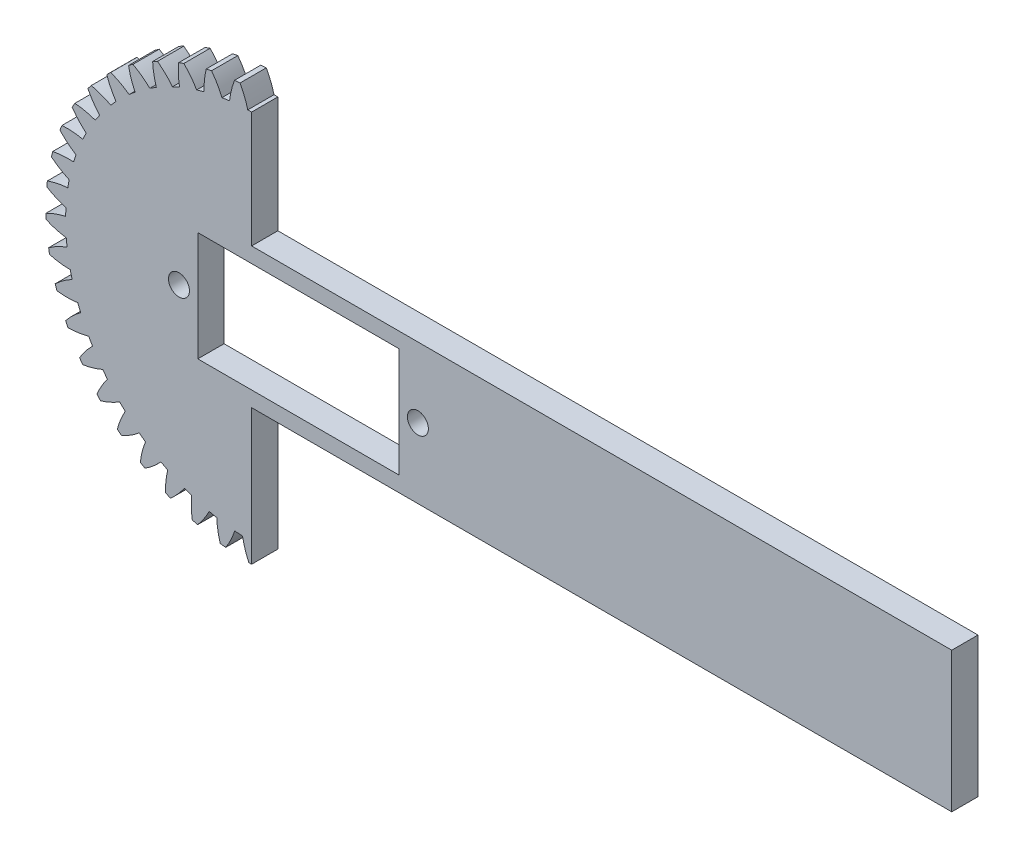
from build123d import *

# Parameters (mm, degrees)
MODEL_R             = 2.5
BOSS_EXTRUDE1_DEPTH = 3
CUT_EXTRUDE1_DEPTH  = 3
SKETCH5_W           = 82.5
SKETCH5_H           = 16
BOSS_EXTRUDE2_DEPTH = 3
SKETCH6_R           = 1.2
SKETCH6_W           = 23
SKETCH6_H           = 12.5
CUT_EXTRUDE3_DEPTH  = 3


with BuildPart() as part:
    # Model → Boss-Extrude1 (new body)
    with BuildSketch(Plane.XY):
        with BuildLine():
            ThreePointArc((32.442634493, 93.418604181), (32.407825649, 93.107382285), (32.377167165, 92.795724168))
            ThreePointArc((32.377167165, 92.795724168), (33.438114337, 92.242398237), (34.563087863, 91.834705887))
            ThreePointArc((34.563087863, 91.834705887), (34.543034507, 91.392542803), (34.532195277, 90.950057955))
            ThreePointArc((34.532195277, 90.950057955), (33.381522949, 90.62183291), (32.284562125, 90.143862787))
            ThreePointArc((32.284562125, 90.143862787), (32.293405755, 89.830825225), (32.306420064, 89.517933307))
            ThreePointArc((32.306420064, 89.517933307), (33.434050257, 89.117647614), (34.604815427, 88.870488953))
            ThreePointArc((34.604815427, 88.870488953), (34.646494435, 88.429838082), (34.697342681, 87.990150937))
            ThreePointArc((34.697342681, 87.990150937), (33.603548714, 87.504977519), (32.583784022, 86.878991529))
            ThreePointArc((32.583784022, 86.878991529), (32.636107994, 86.570231223), (32.692541788, 86.262195589))
            ThreePointArc((32.692541788, 86.262195589), (33.864906962, 86.02274124), (35.058676163, 85.940926928))
            ThreePointArc((35.058676163, 85.940926928), (35.161276302, 85.510365038), (35.272822319, 85.082033606))
            ThreePointArc((35.272822319, 85.082033606), (34.25719617, 84.449355164), (33.334476169, 83.687537413))
            ThreePointArc((33.334476169, 83.687537413), (33.429262057, 83.38906403), (33.528016915, 83.091880244))
            ThreePointArc((33.528016915, 83.091880244), (34.722298316, 83.017917945), (35.915836189, 83.103040406))
            ThreePointArc((35.915836189, 83.103040406), (36.077360464, 82.690947894), (36.247433137, 82.282309159))
            ThreePointArc((36.247433137, 82.282309159), (35.329742812, 81.51444006), (34.522027197, 80.631618462))
            ThreePointArc((34.522027197, 80.631618462), (34.657430102, 80.349241448), (34.796583874, 80.068693854))
            ThreePointArc((34.796583874, 80.068693854), (35.989536173, 80.161663197), (37.15961186, 80.412065619))
            ThreePointArc((37.15961186, 80.412065619), (37.376916385, 80.026463398), (37.602205442, 79.645471048))
            ThreePointArc((37.602205442, 79.645471048), (36.800312739, 78.75735699), (36.123322777, 77.770714665))
            ThreePointArc((36.123322777, 77.770714665), (36.296707235, 77.509930166), (36.47355145, 77.251479304))
            ThreePointArc((36.47355145, 77.251479304), (37.641955188, 77.509570746), (38.765794497, 77.920379331))
            ThreePointArc((38.765794497, 77.920379331), (39.034649686, 77.568772709), (39.310770133, 77.222842327))
            ThreePointArc((39.310770133, 77.222842327), (38.640282982, 76.23176944), (38.107195512, 75.160510257))
            ThreePointArc((38.107195512, 75.160510257), (38.315186791, 74.926394148), (38.526279379, 74.69507047))
            ThreePointArc((38.526279379, 74.69507047), (39.647392905, 75.113260555), (40.703121583, 75.676479381))
            ThreePointArc((40.703121583, 75.676479381), (41.018294476, 75.36571198), (41.339871941, 75.061576708))
            ThreePointArc((41.339871941, 75.061576708), (40.813840612, 73.986835098), (40.435031575, 72.8518099))
            ThreePointArc((40.435031575, 72.8518099), (40.673581362, 72.648918985), (40.914813645, 72.449224943))
            ThreePointArc((40.914813645, 72.449224943), (41.966815761, 73.019374077), (42.933885249, 73.724040729))
            ThreePointArc((42.933885249, 73.724040729), (43.289241364, 73.460161284), (43.650016708, 73.203740769))
            ThreePointArc((43.650016708, 73.203740769), (43.278679803, 72.066249059), (43.061522286, 70.88954982))
            ThreePointArc((43.061522286, 70.88954982), (43.32598748, 70.721833138), (43.592664146, 70.55765555))
            ThreePointArc((43.592664146, 70.55765555), (44.555078827, 71.268666428), (45.414666218, 72.101065373))
            ThreePointArc((45.414666218, 72.101065373), (45.803288952, 71.889209997), (46.196240094, 71.685495172))
            ThreePointArc((46.196240094, 71.685495172), (45.986825262, 70.507393345), (45.935545989, 69.311923176))
            ThreePointArc((45.935545989, 69.311923176), (46.220779078, 69.182645143), (46.507709568, 69.057179538))
            ThreePointArc((46.507709568, 69.057179538), (47.361804507, 69.895213143), (48.09717891, 70.839142682))
            ThreePointArc((48.09717891, 70.839142682), (48.511504164, 70.683434899), (48.928982756, 70.536390841))
            ThreePointArc((48.928982756, 70.536390841), (48.88556602, 69.340609308), (49.001163084, 68.149636678))
            ThreePointArc((49.001163084, 68.149636678), (49.301612328, 68.061313543), (49.603211868, 67.977001967))
            ThreePointArc((49.603211868, 67.977001967), (50.332363078, 68.925746928), (50.929211268, 69.962834545))
            ThreePointArc((50.929211268, 69.962834545), (51.361174672, 69.86630503), (51.795054968, 69.778793785))
            ThreePointArc((51.795054968, 69.778793785), (51.918481385, 68.588607074), (52.19870482, 67.42531291))
            ThreePointArc((52.19870482, 67.42531291), (52.508522317, 67.379663782), (52.818920615, 67.338147264))
            ThreePointArc((52.818920615, 67.338147264), (53.408935997, 68.379137339), (53.855641001, 69.489197304))
            ThreePointArc((53.855641001, 69.489197304), (54.296834879, 69.453724894), (54.738671894, 69.427449769))
            ThreePointArc((54.738671894, 69.427449769), (55.026539108, 68.26602351), (55.465934684, 67.153050009))
            ThreePointArc((55.465934684, 67.153050009), (55.77909019, 67.150963398), (56.092245695, 67.153050009))
            ThreePointArc((56.092245695, 67.153050009), (56.531641271, 68.26602351), (56.819508486, 69.427449769))
            ThreePointArc((56.819508486, 69.427449769), (57.2613455, 69.453724894), (57.702539378, 69.489197304))
            ThreePointArc((57.702539378, 69.489197304), (58.149244383, 68.379137339), (58.739259765, 67.338147264))
            ThreePointArc((58.739259765, 67.338147264), (59.049658062, 67.379663782), (59.35947556, 67.42531291))
            ThreePointArc((59.35947556, 67.42531291), (59.639698995, 68.588607074), (59.763125412, 69.778793785))
            ThreePointArc((59.763125412, 69.778793785), (60.197005708, 69.86630503), (60.628969112, 69.962834545))
            ThreePointArc((60.628969112, 69.962834545), (61.225817302, 68.925746928), (61.954968511, 67.977001967))
            ThreePointArc((61.954968511, 67.977001967), (62.256568052, 68.061313543), (62.557017296, 68.149636678))
            ThreePointArc((62.557017296, 68.149636678), (62.672614359, 69.340609308), (62.629197623, 70.536390841))
            ThreePointArc((62.629197623, 70.536390841), (63.046676215, 70.683434899), (63.461001469, 70.839142682))
            ThreePointArc((63.461001469, 70.839142682), (64.196375873, 69.895213143), (65.050470811, 69.057179538))
            ThreePointArc((65.050470811, 69.057179538), (65.337401302, 69.182645143), (65.622634391, 69.311923176))
            ThreePointArc((65.622634391, 69.311923176), (65.571355117, 70.507393345), (65.361940286, 71.685495172))
            ThreePointArc((65.361940286, 71.685495172), (65.754891428, 71.889209997), (66.143514162, 72.101065373))
            ThreePointArc((66.143514162, 72.101065373), (67.003101553, 71.268666428), (67.965516234, 70.55765555))
            ThreePointArc((67.965516234, 70.55765555), (68.232192899, 70.721833138), (68.496658094, 70.88954982))
            ThreePointArc((68.496658094, 70.88954982), (68.279500577, 72.066249059), (67.908163672, 73.203740769))
            ThreePointArc((67.908163672, 73.203740769), (68.268939016, 73.460161284), (68.624295131, 73.724040729))
            ThreePointArc((68.624295131, 73.724040729), (69.591364619, 73.019374077), (70.643366735, 72.449224943))
            ThreePointArc((70.643366735, 72.449224943), (70.884599018, 72.648918985), (71.123148805, 72.8518099))
            ThreePointArc((71.123148805, 72.8518099), (70.744339767, 73.986835098), (70.218308439, 75.061576708))
            ThreePointArc((70.218308439, 75.061576708), (70.539885904, 75.36571198), (70.855058797, 75.676479381))
            ThreePointArc((70.855058797, 75.676479381), (71.910787474, 75.113260555), (73.031901001, 74.69507047))
            ThreePointArc((73.031901001, 74.69507047), (73.242993589, 74.926394148), (73.450984868, 75.160510257))
            ThreePointArc((73.450984868, 75.160510257), (72.917897397, 76.23176944), (72.247410247, 77.222842327))
            ThreePointArc((72.247410247, 77.222842327), (72.523530693, 77.568772709), (72.792385882, 77.920379331))
            ThreePointArc((72.792385882, 77.920379331), (73.916225192, 77.509570746), (75.084628929, 77.251479304))
            ThreePointArc((75.084628929, 77.251479304), (75.261473145, 77.509930166), (75.434857602, 77.770714665))
            ThreePointArc((75.434857602, 77.770714665), (74.75786764, 78.75735699), (73.955974938, 79.645471048))
            ThreePointArc((73.955974938, 79.645471048), (74.181263995, 80.026463398), (74.39856852, 80.412065619))
            ThreePointArc((74.39856852, 80.412065619), (75.568644207, 80.161663197), (76.761596506, 80.068693855))
            ThreePointArc((76.761596506, 80.068693855), (76.900750278, 80.349241448), (77.036153182, 80.631618462))
            ThreePointArc((77.036153182, 80.631618462), (76.228437568, 81.51444006), (75.310747243, 82.282309159))
            ThreePointArc((75.310747243, 82.282309159), (75.480819916, 82.690947894), (75.642344191, 83.103040406))
            ThreePointArc((75.642344191, 83.103040406), (76.835882063, 83.017917945), (78.030163465, 83.091880244))
            ThreePointArc((78.030163465, 83.091880244), (78.128918323, 83.38906403), (78.223704211, 83.687537413))
            ThreePointArc((78.223704211, 83.687537413), (77.30098421, 84.449355164), (76.28535806, 85.082033606))
            ThreePointArc((76.28535806, 85.082033606), (76.396904078, 85.510365038), (76.499504217, 85.940926928))
            ThreePointArc((76.499504217, 85.940926928), (77.693273418, 86.02274124), (78.865638592, 86.262195589))
            ThreePointArc((78.865638592, 86.262195589), (78.922072386, 86.570231223), (78.974396358, 86.878991529))
            ThreePointArc((78.974396358, 86.878991529), (77.954631666, 87.504977519), (76.860837699, 87.990150937))
            ThreePointArc((76.860837699, 87.990150937), (76.911685945, 88.429838082), (76.953364953, 88.870488953))
            ThreePointArc((76.953364953, 88.870488953), (78.124130123, 89.117647614), (79.251760315, 89.517933307))
            ThreePointArc((79.251760315, 89.517933307), (79.264774625, 89.830825225), (79.273618254, 90.143862787))
            ThreePointArc((79.273618254, 90.143862787), (78.176657431, 90.62183291), (77.025985103, 90.950057955))
            ThreePointArc((77.025985103, 90.950057955), (77.015145873, 91.392542803), (76.995092516, 91.834705887))
            ThreePointArc((76.995092516, 91.834705887), (78.120066043, 92.242398237), (79.181013214, 92.795724168))
            ThreePointArc((79.181013214, 92.795724168), (79.150354731, 93.107382285), (79.115545887, 93.418604181))
            ThreePointArc((79.115545887, 93.418604181), (77.962740026, 93.739255293), (76.777585865, 93.904143438))
            ThreePointArc((76.777585865, 93.904143438), (76.705270134, 94.340813525), (76.623874727, 94.77588262))
            ThreePointArc((76.623874727, 94.77588262), (77.68116028, 95.33617339), (78.654774301, 96.031769699))
            ThreePointArc((78.654774301, 96.031769699), (78.581039757, 96.336127944), (78.503255954, 96.639476596))
            ThreePointArc((78.503255954, 96.639476596), (77.317043112, 96.796567587), (76.120474794, 96.794909472))
            ThreePointArc((76.120474794, 96.794909472), (75.988090105, 97.217265511), (75.846936918, 97.636772493))
            ThreePointArc((75.846936918, 97.636772493), (76.815955636, 98.33875626), (77.683286217, 99.163083956))
            ThreePointArc((77.683286217, 99.163083956), (77.567910772, 99.454218343), (77.448665983, 99.743789414))
            ThreePointArc((77.448665983, 99.743789414), (76.252134442, 99.734262685), (75.06744181, 99.566090585))
            ThreePointArc((75.06744181, 99.566090585), (74.87756488, 99.965911896), (74.679401298, 100.361691538))
            ThreePointArc((74.679401298, 100.361691538), (75.541292335, 101.191704987), (76.285457873, 102.128719469))
            ThreePointArc((76.285457873, 102.128719469), (76.130687179, 102.400963398), (75.972302368, 102.671120715))
            ThreePointArc((75.972302368, 102.671120715), (74.788741254, 102.495161696), (73.638983002, 102.163748887))
            ThreePointArc((73.638983002, 102.163748887), (73.395309569, 102.533253404), (73.143992622, 102.897602305))
            ThreePointArc((73.143992622, 102.897602305), (73.881980249, 103.839490169), (74.488496408, 104.870953516))
            ThreePointArc((74.488496408, 104.870953516), (74.2973429, 105.119008068), (74.102900847, 105.364493328))
            ThreePointArc((74.102900847, 105.364493328), (72.955346831, 105.025526859), (71.862901696, 104.537323916))
            ThreePointArc((71.862901696, 104.537323916), (71.570174586, 104.869319652), (71.270595872, 105.195146176))
            ThreePointArc((71.270595872, 105.195146176), (71.870316, 106.230575679), (72.327377633, 107.33641163))
            ThreePointArc((72.327377633, 107.33641163), (72.103561896, 107.555448706), (71.876847195, 107.771483817))
            ThreePointArc((71.876847195, 107.771483817), (70.78763611, 107.276107495), (69.773767294, 106.640616732))
            ThreePointArc((69.773767294, 106.640616732), (69.437684108, 106.92864177), (69.095674586, 107.209604074))
            ThreePointArc((69.095674586, 107.209604074), (69.545454343, 108.318421758), (69.844165265, 109.477106474))
            ThreePointArc((69.844165265, 109.477106474), (69.592043619, 109.662862766), (69.337469014, 109.84524285))
            ThreePointArc((69.337469014, 109.84524285), (68.327801115, 109.203098612), (67.41224242, 108.432689135))
            ThreePointArc((67.41224242, 108.432689135), (67.039344636, 108.671137393), (66.661561131, 108.901766865))
            ThreePointArc((66.661561131, 108.901766865), (66.952646068, 110.062390856), (67.087192211, 111.251371857))
            ThreePointArc((67.087192211, 111.251371857), (66.811671915, 111.40023183), (66.534192411, 111.545407066))
            ThreePointArc((66.534192411, 111.545407066), (65.623719736, 110.76899352), (64.824291471, 109.878660472))
            ThreePointArc((64.824291471, 109.878660472), (64.421837119, 110.062890827), (64.015632758, 110.238698528))
            ThreePointArc((64.015632758, 110.238698528), (64.142357237, 111.428538598), (64.110119813, 112.624673722))
            ThreePointArc((64.110119813, 112.624673722), (63.816563558, 112.733739986), (63.521579977, 112.838884704))
            ThreePointArc((63.521579977, 112.838884704), (62.72802384, 111.943313856), (62.060285968, 110.950386557))
            ThreePointArc((62.060285968, 110.950386557), (61.636108364, 111.076813175), (61.209389454, 111.194377206))
            ThreePointArc((61.209389454, 111.194377206), (61.169286926, 112.390274474), (60.9708934, 113.570282311))
            ThreePointArc((60.9708934, 113.570282311), (60.665014924, 113.637432015), (60.358268787, 113.700499692))
            ThreePointArc((60.358268787, 113.700499692), (59.697074856, 112.703202809), (59.174024134, 111.627007461))
            ThreePointArc((59.174024134, 111.627007461), (58.736379412, 111.693169591), (58.29745155, 111.750201703))
            ThreePointArc((58.29745155, 111.750201703), (58.091302566, 112.928879387), (57.730614443, 114.069792427))
            ThreePointArc((57.730614443, 114.069792427), (57.418367323, 114.093718579), (57.105829094, 114.113481674))
            ThreePointArc((57.105829094, 114.113481674), (56.589866756, 113.033870007), (56.221683772, 111.895353526))
            ThreePointArc((56.221683772, 111.895353526), (55.77909019, 111.899963398), (55.336496608, 111.895353526))
            ThreePointArc((55.336496608, 111.895353526), (54.968313623, 113.033870007), (54.452351286, 114.113481674))
            ThreePointArc((54.452351286, 114.113481674), (54.139813057, 114.093718579), (53.827565937, 114.069792427))
            ThreePointArc((53.827565937, 114.069792427), (53.466877813, 112.928879387), (53.260728829, 111.750201703))
            ThreePointArc((53.260728829, 111.750201703), (52.821800968, 111.693169591), (52.384156246, 111.62700746))
            ThreePointArc((52.384156246, 111.62700746), (51.861105524, 112.703202809), (51.199911593, 113.700499692))
            ThreePointArc((51.199911593, 113.700499692), (50.893165456, 113.637432015), (50.58728698, 113.570282311))
            ThreePointArc((50.58728698, 113.570282311), (50.388893454, 112.390274474), (50.348790926, 111.194377206))
            ThreePointArc((50.348790926, 111.194377206), (49.922072016, 111.076813175), (49.497894412, 110.950386557))
            ThreePointArc((49.497894412, 110.950386557), (48.830156539, 111.943313856), (48.036600402, 112.838884704))
            ThreePointArc((48.036600402, 112.838884704), (47.741616822, 112.733739986), (47.448060567, 112.624673722))
            ThreePointArc((47.448060567, 112.624673722), (47.415823143, 111.428538598), (47.542547621, 110.238698528))
            ThreePointArc((47.542547621, 110.238698528), (47.136343261, 110.062890827), (46.733888909, 109.878660472))
            ThreePointArc((46.733888909, 109.878660472), (45.934460644, 110.76899352), (45.023987969, 111.545407066))
            ThreePointArc((45.023987969, 111.545407066), (44.746508464, 111.40023183), (44.470988169, 111.251371857))
            ThreePointArc((44.470988169, 111.251371857), (44.605534312, 110.062390856), (44.896619249, 108.901766865))
            ThreePointArc((44.896619249, 108.901766865), (44.518835744, 108.671137393), (44.145937959, 108.432689135))
            ThreePointArc((44.145937959, 108.432689135), (43.230379265, 109.203098612), (42.220711366, 109.84524285))
            ThreePointArc((42.220711366, 109.84524285), (41.966136761, 109.662862766), (41.714015114, 109.477106474))
            ThreePointArc((41.714015114, 109.477106474), (42.012726036, 108.318421758), (42.462505794, 107.209604074))
            ThreePointArc((42.462505794, 107.209604074), (42.120496272, 106.92864177), (41.784413086, 106.640616732))
            ThreePointArc((41.784413086, 106.640616732), (40.770544269, 107.276107495), (39.681333185, 107.771483817))
            ThreePointArc((39.681333185, 107.771483817), (39.454618484, 107.555448706), (39.230802747, 107.33641163))
            ThreePointArc((39.230802747, 107.33641163), (39.68786438, 106.230575679), (40.287584507, 105.195146176))
            ThreePointArc((40.287584507, 105.195146176), (39.988005793, 104.869319652), (39.695278684, 104.537323916))
            ThreePointArc((39.695278684, 104.537323916), (38.602833549, 105.025526859), (37.455279533, 105.364493328))
            ThreePointArc((37.455279533, 105.364493328), (37.26083748, 105.119008068), (37.069683972, 104.870953516))
            ThreePointArc((37.069683972, 104.870953516), (37.676200131, 103.839490169), (38.414187758, 102.897602305))
            ThreePointArc((38.414187758, 102.897602305), (38.162870811, 102.533253404), (37.919197377, 102.163748887))
            ThreePointArc((37.919197377, 102.163748887), (36.769439126, 102.495161696), (35.585878012, 102.671120715))
            ThreePointArc((35.585878012, 102.671120715), (35.427493201, 102.400963398), (35.272722506, 102.128719469))
            ThreePointArc((35.272722506, 102.128719469), (36.016888044, 101.191704987), (36.878779081, 100.361691538))
            ThreePointArc((36.878779081, 100.361691538), (36.6806155, 99.965911896), (36.490738569, 99.566090585))
            ThreePointArc((36.490738569, 99.566090585), (35.306045938, 99.734262685), (34.109514397, 99.743789414))
            ThreePointArc((34.109514397, 99.743789414), (33.990269608, 99.454218343), (33.874894163, 99.163083956))
            ThreePointArc((33.874894163, 99.163083956), (34.742224744, 98.33875626), (35.711243462, 97.636772493))
            ThreePointArc((35.711243462, 97.636772493), (35.570090275, 97.217265511), (35.437705585, 96.794909472))
            ThreePointArc((35.437705585, 96.794909472), (34.241137268, 96.796567587), (33.054924426, 96.639476596))
            ThreePointArc((33.054924426, 96.639476596), (32.977140622, 96.336127944), (32.903406079, 96.031769699))
            ThreePointArc((32.903406079, 96.031769699), (33.8770201, 95.33617339), (34.934305652, 94.77588262))
            ThreePointArc((34.934305652, 94.77588262), (34.852910246, 94.340813525), (34.780594515, 93.904143438))
            ThreePointArc((34.780594515, 93.904143438), (33.595440353, 93.739255293), (32.442634493, 93.418604181))
        make_face()
        with Locations((55.77909019, 90.650963398)):
            Circle(MODEL_R, mode=Mode.SUBTRACT)
    extrude(amount=BOSS_EXTRUDE1_DEPTH)

    # Sketch2 → Cut-Extrude1 (cut)
    with BuildSketch(Plane.XY.offset(3)):
        Polygon((55.77909019, 90.650963398), (55.77909019, 117.159846612), (88.792970811, 117.159846612), (88.792970811, 58.04558037), (55.77909019, 58.04558037), align=None)
    extrude(amount=-CUT_EXTRUDE1_DEPTH, mode=Mode.SUBTRACT)

    # Sketch5 → Boss-Extrude2 (add)
    with BuildSketch(Plane.XY):
        with Locations((94.52909019, 90.650963398)):
            Rectangle(SKETCH5_W, SKETCH5_H)
    extrude(amount=BOSS_EXTRUDE2_DEPTH)

    # Sketch6 → Cut-Extrude3 (cut)
    with BuildSketch(Plane.XY.offset(3)):
        with Locations((47.47909019, 90.650963398)):
            Circle(SKETCH6_R)
        with Locations((74.77909019, 90.650963398)):
            Circle(SKETCH6_R)
        with Locations((61.12909019, 90.650963398)):
            Rectangle(SKETCH6_W, SKETCH6_H)
    extrude(amount=-CUT_EXTRUDE3_DEPTH, mode=Mode.SUBTRACT)


solid = part.part
